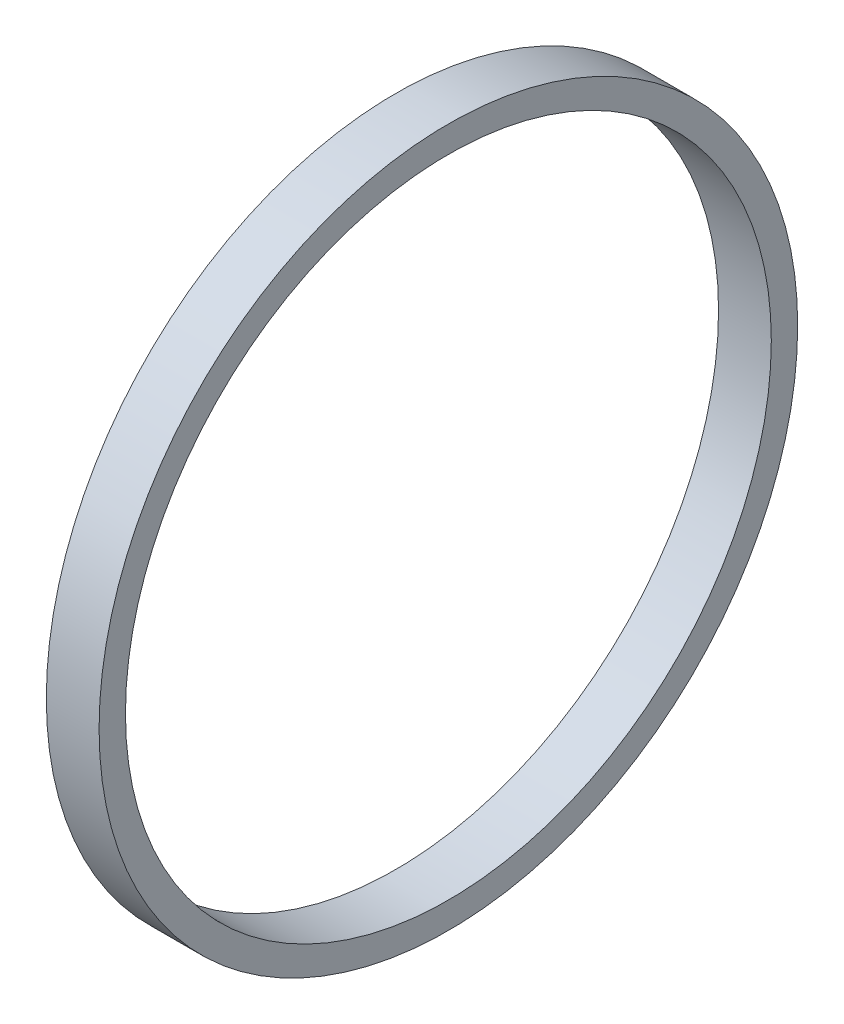
from build123d import *

# Parameters (mm, degrees)
SKETCH1_R           = 21.021184884
SKETCH1_R_2         = 19.433684884
BOSS_EXTRUDE1_DEPTH = 3.175


with BuildPart() as part:
    # Sketch1 → Boss-Extrude1 (new body)
    with BuildSketch(Plane(origin=(0, 0, 0), x_dir=(0, 0, -1), z_dir=(1, 0, 0))):
        Circle(SKETCH1_R)
        Circle(SKETCH1_R_2, mode=Mode.SUBTRACT)
    extrude(amount=BOSS_EXTRUDE1_DEPTH)


solid = part.part
